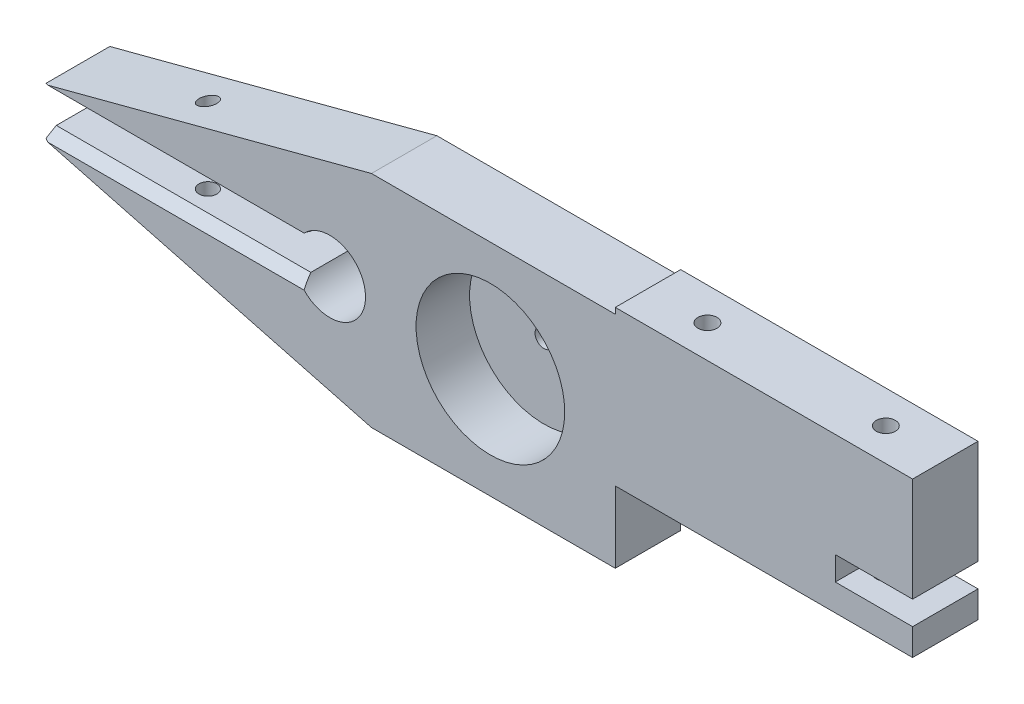
from build123d import *

# Parameters (mm, degrees)
EXTRUDE1_DEPTH          = 5.5
SKETCH2_R               = 1.6
SKETCH2_R_2             = 1.5
CUT_EXTRUDE1_DEPTH      = 20.5
CUT_EXTRUDE1_DEPTH_BACK = 19.5
CHAMFER1_SIZE           = 2
CHAMFER1_SIZE2          = 1.154700538
CHAMFER1_PART_2_SIZE    = 2
CHAMFER1_PART_2_SIZE2   = 1.154700538


with BuildPart() as part:
    # Sketch1 → Extrude1 (new body, symmetric)
    with BuildSketch(Plane.XY):
        with BuildLine():
            Line((61, -2), (61, -6.5))
            Line((61, -6.5), (11, -6.5))
            Line((11, -6.5), (11, -18.5))
            Line((11, -18.5), (-30, -18.5))
            Line((-30, -18.5), (-85, -4))
            Line((-85, -4), (-85, -3))
            Line((-85, -3), (-42.196152423, -3))
            ThreePointArc((-42.196152423, -3), (-31, 0), (-42.196152423, 3))
            Line((-42.196152423, 3), (-85, 3))
            Line((-85, 3), (-85, 4))
            Line((-85, 4), (-30, 18.5))
            Line((-30, 18.5), (11, 18.5))
            Line((11, 18.5), (11, 19.5))
            Line((11, 19.5), (61, 19.5))
            Line((61, 19.5), (61, 2))
            Line((61, 2), (48, 2))
            Line((48, 2), (48, -2))
            Line((48, -2), (61, -2))
        make_face()
    extrude(amount=EXTRUDE1_DEPTH, both=True)

    # Sketch2 → Cut-Extrude1 (cut, two sides)
    with BuildSketch(Plane(origin=(0, 0, 0), x_dir=(1, 0, 0), z_dir=(0, 1, 0))) as cut_extrude1_sk:
        with Locations(Location((21, 0, 0), (0, 0, 270))):  # turned: the seam where the file's is
            Circle(SKETCH2_R)
        with Locations(Location((51, 0, 0), (0, 0, 270))):  # turned: the seam where the file's is
            Circle(SKETCH2_R)
        with Locations((-63, 0)):
            Circle(SKETCH2_R_2)
    extrude(amount=CUT_EXTRUDE1_DEPTH, mode=Mode.SUBTRACT)
    extrude(cut_extrude1_sk.sketch, amount=-CUT_EXTRUDE1_DEPTH_BACK, mode=Mode.SUBTRACT)

    # Chamfer1
    chamfer1_edges = [part.edges().sort_by_distance(p)[0] for p in [
        (-63.598076211, -3, 5.5),
    ]]
    chamfer1_side = [part.faces().sort_by_distance(p)[0] for p in [
        (-63.598076211, -3, -5.058053242),
    ]]
    chamfer(chamfer1_edges, length=CHAMFER1_SIZE, length2=CHAMFER1_SIZE2, reference=chamfer1_side[0])

    # Chamfer1 part 2
    chamfer1_part_2_edges = [part.edges().sort_by_distance(p)[0] for p in [
        (-63.598076211, 3, 5.5),
    ]]
    chamfer1_part_2_side = [part.faces().sort_by_distance(p)[0] for p in [
        (-63.598076211, 3, -5.058053242),
    ]]
    chamfer(chamfer1_part_2_edges, length=CHAMFER1_PART_2_SIZE, length2=CHAMFER1_PART_2_SIZE2, reference=chamfer1_part_2_side[0])

    # Sketch3 → Cut-Revolve1 (revolve, cut)
    with BuildSketch(Plane(origin=(0, 0, 0), x_dir=(1, 0, 0), z_dir=(0, 1, 0))):
        Polygon((-10, 5.5), (-8.5, 5.5), (-8.5, 3.5), (2.5, 3.5), (2.5, -5.5), (-10, -5.5), align=None)
    revolve(axis=Axis((-10, 0, -5.5), (0, 0, -1)), mode=Mode.SUBTRACT)


solid = part.part
